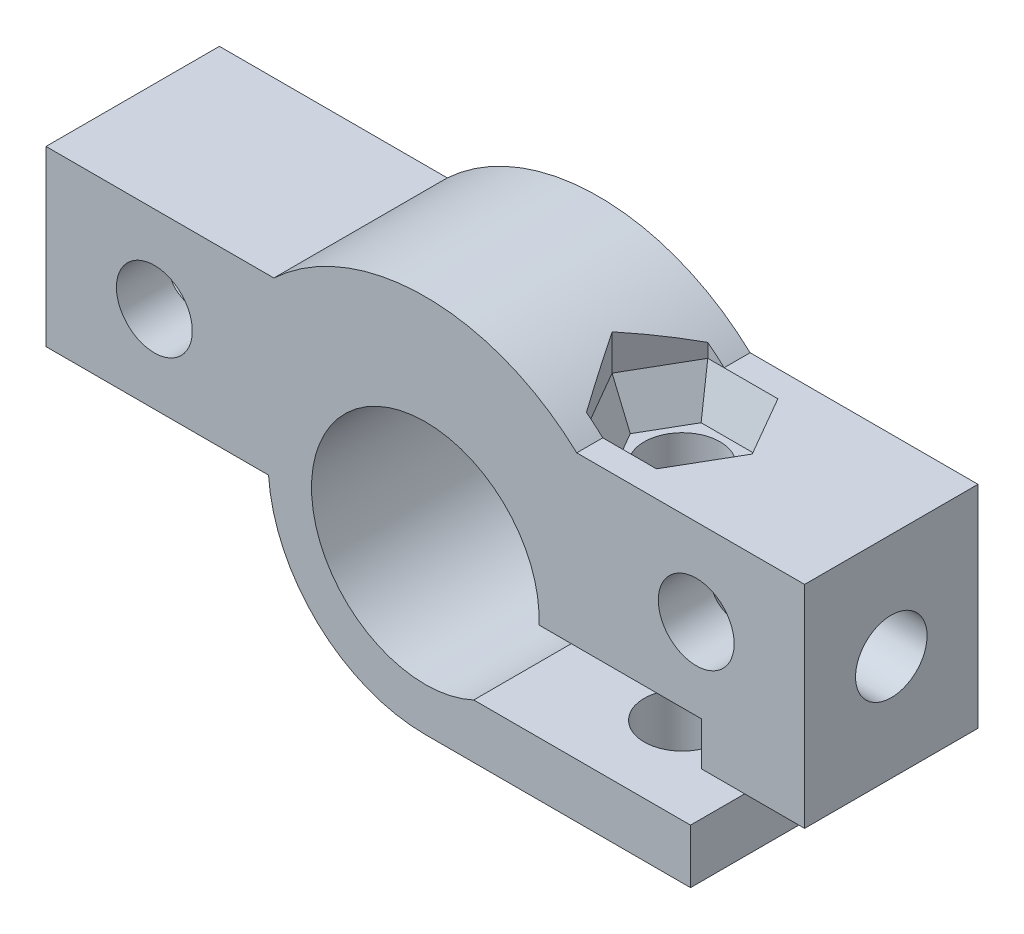
from build123d import *

# Parameters (mm, degrees)
ESBO_O1_R                       = 1.75
RESSALTO_EXTRUS_O1_DEPTH        = 8
ESBO_O2_R                       = 1.65
CORTE_EXTRUS_O1_DEPTH           = 7
ESBO_O3_R                       = 1.75
CORTE_EXTRUS_O2_DEPTH           = 18.5
CORTE_EXTRUS_O3_DEPTH           = 2
CORTE_EXTRUS_O3_TAPER           = 20
CORTE_EXTRUS_O3_OTHER_WAY_DEPTH = 6


with BuildPart() as part:
    # Esboço1 → Ressalto-extrusão1 (new body)
    with BuildSketch(Plane.XY):
        with BuildLine():
            Line((17.5, 7.5), (6.986594306, 7.5))
            ThreePointArc((6.986594306, 7.5), (0, 10.25), (-6.986594306, 7.5))
            Line((-6.986594306, 7.5), (-17.5, 7.5))
            Line((-17.5, 7.5), (-17.5, -0.5))
            Line((-17.5, -0.5), (-7.232738071, -0.5))
            ThreePointArc((-7.232738071, -0.5), (-4.946589734, -5.300353762), (0, -7.25))
            Line((0, -7.25), (12.236067977, -7.25))
            Line((12.236067977, -7.25), (12.236067977, -4.75))
            Line((12.236067977, -4.75), (2.236067977, -4.75))
            ThreePointArc((2.236067977, -4.75), (-4.364690104, 2.917529829), (5.244044241, -0.25))
            Line((5.244044241, -0.25), (12.736067977, -0.25))
            Line((12.736067977, -0.25), (12.736067977, -2.25))
            Line((12.736067977, -2.25), (15.807189139, -2.25))
            Line((15.807189139, -2.25), (17.5, -2.25))
            Line((17.5, -2.25), (17.5, 7.5))
        make_face()
        with Locations((12.5, 3.5)):
            Circle(ESBO_O1_R, mode=Mode.SUBTRACT)
        with Locations((-12.5, 3.5)):
            Circle(ESBO_O1_R, mode=Mode.SUBTRACT)
    extrude(amount=RESSALTO_EXTRUS_O1_DEPTH)

    # Esboço2 → Corte-extrusão1 (cut)
    with BuildSketch(Plane(origin=(17.5, 0, 0), x_dir=(0, 0, -1), z_dir=(1, 0, 0))):
        with Locations((-4, 2.625)):
            Circle(ESBO_O2_R)
    corte_extrus_o1 = extrude(amount=-CORTE_EXTRUS_O1_DEPTH, mode=Mode.SUBTRACT)

    # Espelhar1: Corte-extrusão1 across plane
    add(corte_extrus_o1.mirror(Plane(origin=(0, 0, 0), x_dir=(0, 0, 1), z_dir=(1, 0, 0))), mode=Mode.SUBTRACT)

    # Esboço3 → Corte-extrusão2 (cut, through all)
    with BuildSketch(Plane.XZ.offset(7.25)):
        with Locations((7.85, 4)):
            Circle(ESBO_O3_R)
    extrude(amount=-CORTE_EXTRUS_O2_DEPTH, mode=Mode.SUBTRACT)

    # Esboço4 → Corte-extrusão3 (cut)
    with BuildSketch(Plane(origin=(0, 7.5, 0), x_dir=(1, 0, 0), z_dir=(0, 1, 0))):
        Polygon((11.083161507, -4), (9.466580754, -1.2), (6.233419246, -1.2), (4.616838493, -4), (6.233419246, -6.8), (9.466580754, -6.8), align=None)
    extrude(amount=-CORTE_EXTRUS_O3_DEPTH, taper=CORTE_EXTRUS_O3_TAPER, mode=Mode.SUBTRACT)

    # Esboço4 → Corte-extrusão3 other way (cut)
    with BuildSketch(Plane(origin=(0, 7.5, 0), x_dir=(1, 0, 0), z_dir=(0, 1, 0))):
        Polygon((11.083161507, -4), (9.466580754, -1.2), (6.233419246, -1.2), (4.616838493, -4), (6.233419246, -6.8), (9.466580754, -6.8), align=None)
    extrude(amount=CORTE_EXTRUS_O3_OTHER_WAY_DEPTH, mode=Mode.SUBTRACT)


solid = part.part
